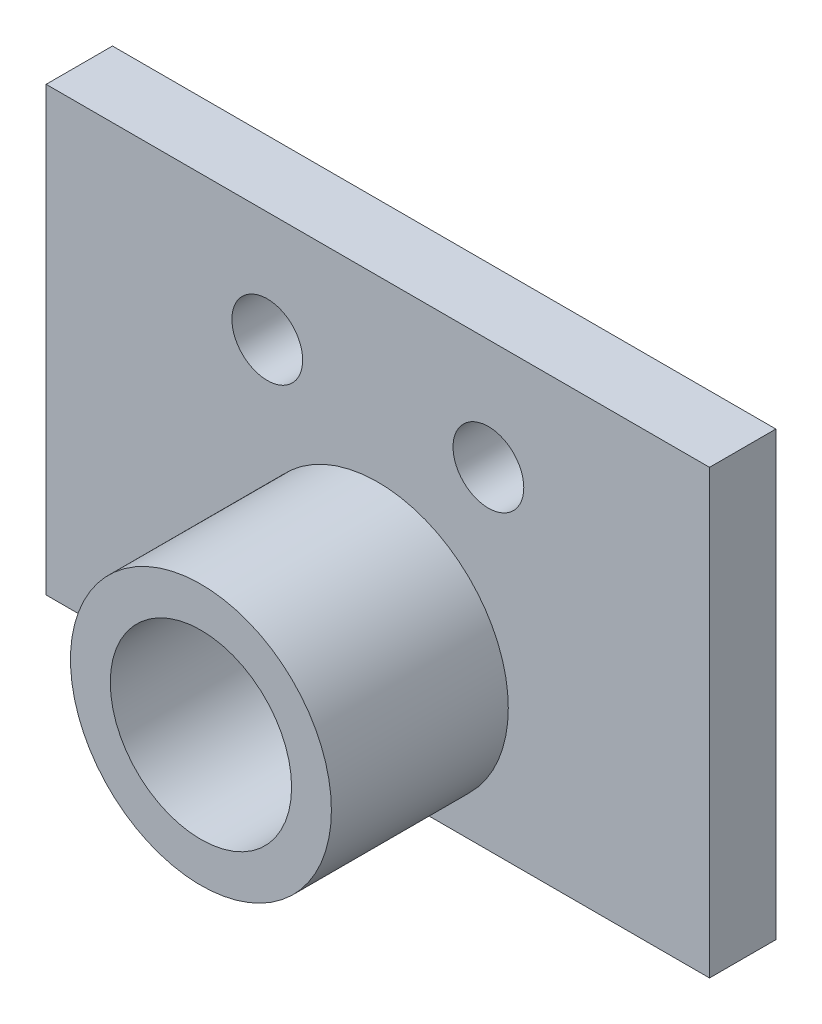
from build123d import *

# Parameters (mm, degrees)
SKETCH_1_W      = 30
SKETCH_1_H      = 20
SKETCH_1_R      = 1.6
SKETCH_1_R_2    = 4.1
EXTRUDE_1_DEPTH = 3
SKETCH_2_R      = 5.9
SKETCH_2_R_2    = 4.1
EXTRUDE_2_DEPTH = 8


with BuildPart() as part:
    # 草图1 → 凸台-拉伸1 (new body)
    with BuildSketch(Plane.XY):
        with Locations((-3.612174849, 26.048923765)):
            Rectangle(SKETCH_1_W, SKETCH_1_H)
        with Locations((-8.612174849, 31.048923765)):
            Circle(SKETCH_1_R, mode=Mode.SUBTRACT)
        with Locations((1.387825151, 31.048923765)):
            Circle(SKETCH_1_R, mode=Mode.SUBTRACT)
        with Locations((-3.612174849, 22.073206433)):
            Circle(SKETCH_1_R_2, mode=Mode.SUBTRACT)
    extrude(amount=EXTRUDE_1_DEPTH)

    # 草图2 → 凸台-拉伸2 (add)
    with BuildSketch(Plane.XY.offset(3)):
        with Locations((-3.612174849, 22.073206433)):
            Circle(SKETCH_2_R)
        with Locations((-3.612174849, 22.073206433)):
            Circle(SKETCH_2_R_2, mode=Mode.SUBTRACT)
    extrude(amount=EXTRUDE_2_DEPTH)


solid = part.part
